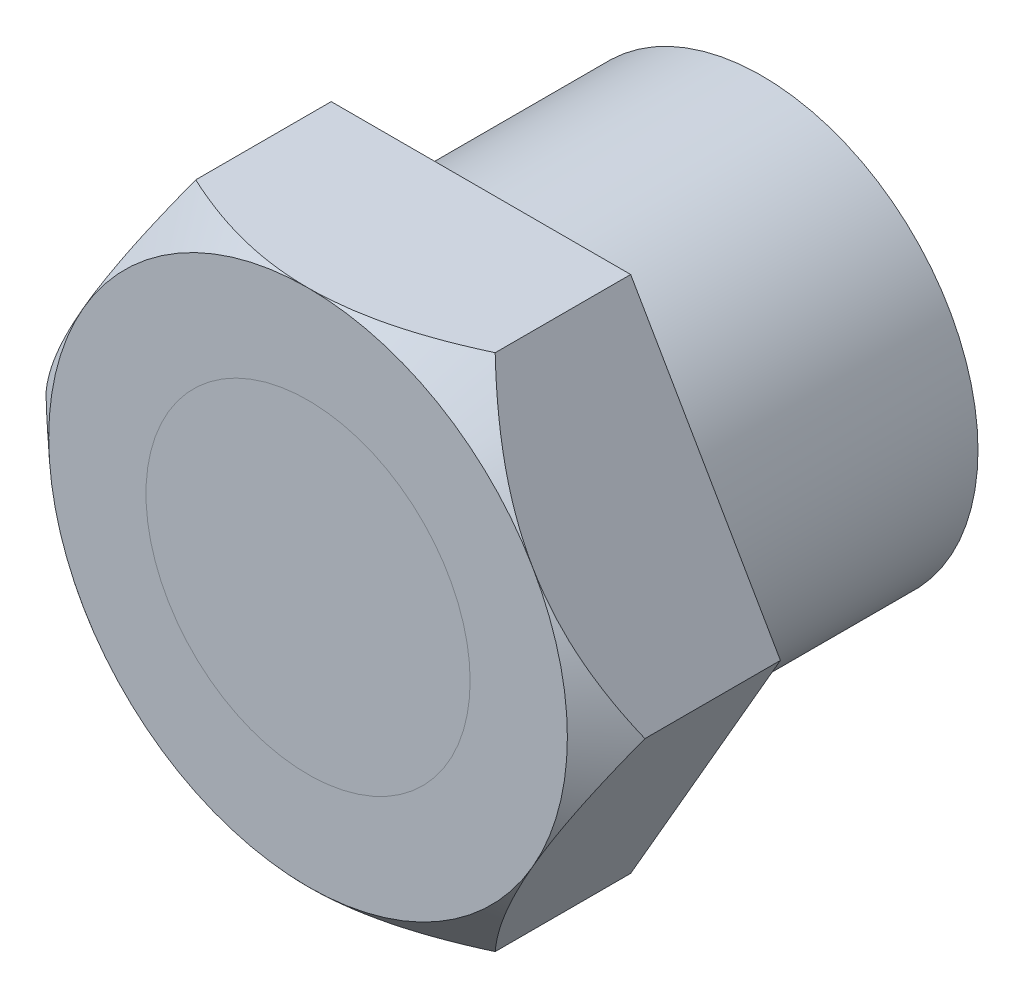
from build123d import *

# Parameters (mm, degrees)
SCHIZZO1_R                   = 10
SCHIZZO1_R_2                 = 7.5
ESTRUSIONE_ESTRUSIONE1_DEPTH = 13
SCHIZZO2_R                   = 7.5
ESTRUSIONE_ESTRUSIONE2_DEPTH = 8
SCHIZZO3_OUTSIDE_W           = 42.452
SCHIZZO3_OUTSIDE_H           = 38.74
SCHIZZO3_OUTSIDE_R           = 12
TAGLIO_ESTRUSIONE1_DEPTH     = 2
TAGLIO_ESTRUSIONE1_TAPER     = 47
SCHIZZO4_R                   = 7.5
ESTRUSIONE_ESTRUSIONE3_DEPTH = 3


with BuildPart() as part:
    # Schizzo1 → Estrusione-Estrusione1 (new body)
    with BuildSketch(Plane.XY):
        Circle(SCHIZZO1_R)
        Circle(SCHIZZO1_R_2, mode=Mode.SUBTRACT)
    extrude(amount=ESTRUSIONE_ESTRUSIONE1_DEPTH)

    # Schizzo2 → Estrusione-Estrusione2 (add)
    with BuildSketch(Plane.XY.offset(13)):
        Polygon((6.92820323, 12), (-6.92820323, 12), (-13.856406461, 0), (-6.92820323, -12), (6.92820323, -12), (13.856406461, 0), align=None)
        Circle(SCHIZZO2_R, mode=Mode.SUBTRACT)
    extrude(amount=ESTRUSIONE_ESTRUSIONE2_DEPTH)

    # Schizzo3 outside → Taglio-Estrusione1 (cut)
    with BuildSketch(Plane.XY.offset(21)):
        Rectangle(SCHIZZO3_OUTSIDE_W, SCHIZZO3_OUTSIDE_H)
        Circle(SCHIZZO3_OUTSIDE_R, mode=Mode.SUBTRACT)
    extrude(amount=-TAGLIO_ESTRUSIONE1_DEPTH, taper=TAGLIO_ESTRUSIONE1_TAPER, mode=Mode.SUBTRACT)


with BuildPart() as body_2:
    # Schizzo4 → Estrusione-Estrusione3 (new body)
    with BuildSketch(Plane.XY.offset(21)):
        Circle(SCHIZZO4_R)
    extrude(amount=-ESTRUSIONE_ESTRUSIONE3_DEPTH)


solid = Compound([part.part, body_2.part])
